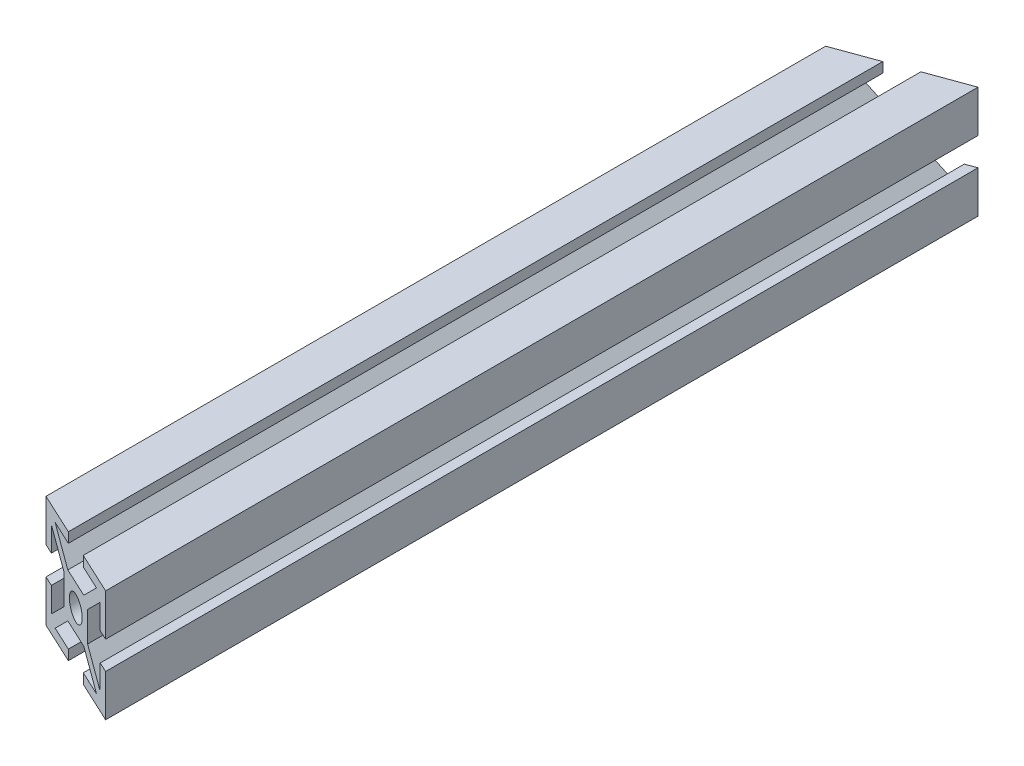
from build123d import *

# Parameters (mm, degrees)
SKETCH2_R           = 2.15
BOSS_EXTRUDE1_DEPTH = 78.1
CUT_EXTRUDE1_DEPTH  = 21
CUT_EXTRUDE2_DEPTH  = 21


with BuildPart() as part:
    # Sketch2 → Boss-Extrude1 (new body, symmetric)
    with BuildSketch(Plane.XY):
        Polygon((-2.5, 10), (-2.5, 8.2), (-6.927207794, 8.2), (-2.677207794, 3.95), (2.677207794, 3.95), (6.927207794, 8.2), (2.5, 8.2), (2.5, 10), (10, 10), (10, 2.5), (8.2, 2.5), (8.2, 6.927207794), (3.95, 2.677207794), (3.95, -2.677207794), (8.2, -6.927207794), (8.2, -2.5), (10, -2.5), (10, -10), (2.5, -10), (2.5, -8.2), (6.927207794, -8.2), (2.677207794, -3.95), (-2.677207794, -3.95), (-6.927207794, -8.2), (-2.5, -8.2), (-2.5, -10), (-10, -10), (-10, -2.5), (-8.2, -2.5), (-8.2, -6.927207794), (-3.95, -2.677207794), (-3.95, 2.677207794), (-8.2, 6.927207794), (-8.2, 2.5), (-10, 2.5), (-10, 10), align=None)
        Circle(SKETCH2_R, mode=Mode.SUBTRACT)
    extrude(amount=BOSS_EXTRUDE1_DEPTH, both=True)

    # Sketch3 → Cut-Extrude1 (cut, through all)
    with BuildSketch(Plane(origin=(0, 10, 0), x_dir=(1, 0, 0), z_dir=(0, 1, 0))):
        Polygon((-10, -78.1), (10, -78.1), (-10, -68.773846837), align=None)
    extrude(amount=-CUT_EXTRUDE1_DEPTH, mode=Mode.SUBTRACT)

    # Sketch4 → Cut-Extrude2 (cut, through all)
    with BuildSketch(Plane(origin=(0, 10, 0), x_dir=(1, 0, 0), z_dir=(0, 1, 0))):
        Polygon((10, 78.1), (-10, 78.1), (-10, 70.820595315), align=None)
    extrude(amount=-CUT_EXTRUDE2_DEPTH, mode=Mode.SUBTRACT)


solid = part.part
